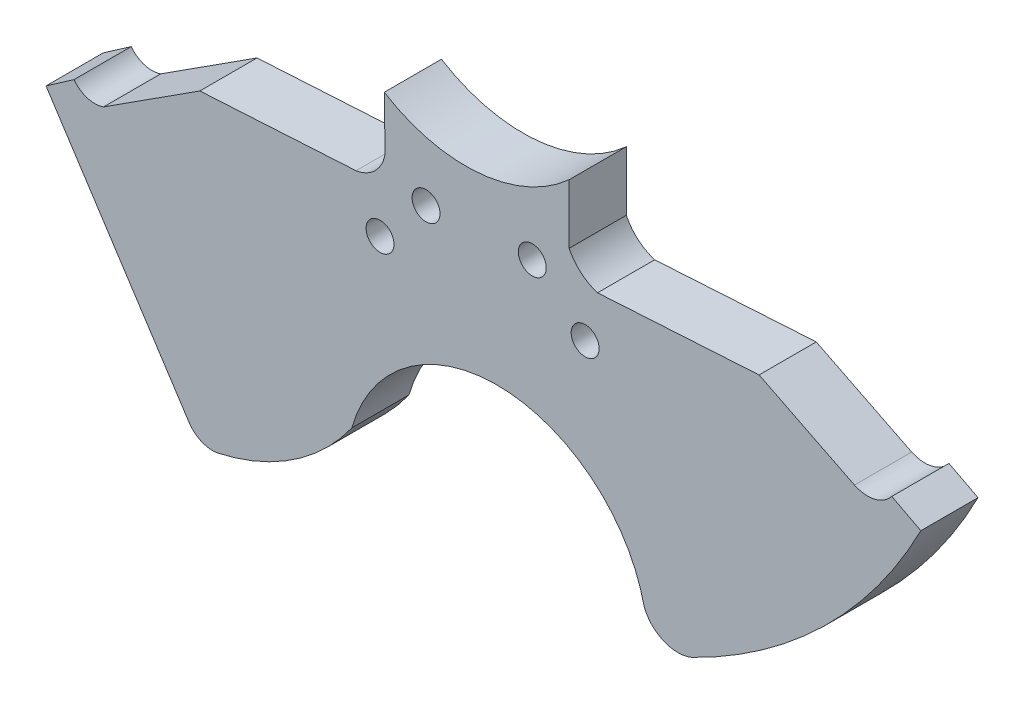
from build123d import *

# Parameters (mm, degrees)
ESBO_O1_R                = 3.175
RESSALTO_EXTRUS_O1_DEPTH = 13


with BuildPart() as part:
    # Esboço1 → Ressalto-extrusão1 (new body)
    with BuildSketch(Plane.XY):
        with BuildLine():
            Line((35.385230037, 10.075467345), (3.022965856, 59.821309359))
            Line((3.022965856, 59.821309359), (9.389592457, 64.241305524))
            ThreePointArc((9.389592457, 64.241305524), (12.424025355, 62.134521854), (16.11664555, 62.238812532))
            Line((16.11664555, 62.238812532), (37.995734983, 76.310625699))
            Line((37.995734983, 76.310625699), (73.510181395, 78.362700262))
            ThreePointArc((73.510181395, 78.362700262), (77.993066809, 80.699414035), (80.140456658, 85.276007717))
            Line((80.140456658, 85.276007717), (79.930003073, 94.415706286))
            Line((79.930003073, 94.415706286), (79.930003073, 97.029046835))
            ThreePointArc((79.930003073, 97.029046835), (101.572218687, 91.878964915), (121.946388489, 100.812163968))
            Line((121.946388489, 100.812163968), (121.946388489, 97.854479056))
            Line((121.946388489, 97.854479056), (121.946388489, 87.306940797))
            ThreePointArc((121.946388489, 87.306940797), (124.605004373, 83.87722317), (128.400566482, 81.773676237))
            Line((128.400566482, 81.773676237), (165.135958914, 83.971302002))
            Line((165.135958914, 83.971302002), (186.825026221, 73.136677472))
            ThreePointArc((186.825026221, 73.136677472), (191.417140339, 72.651683009), (195.305426608, 75.142458308))
            Line((195.305426608, 75.142458308), (201.904648359, 71.689614729))
            ThreePointArc((201.904648359, 71.689614729), (180.384547639, 42.366647273), (150.812504997, 21.190116644))
            ThreePointArc((150.812504997, 21.190116644), (150.313679981, 20.942400372), (149.813666262, 20.697092344))
            ThreePointArc((149.813666262, 20.697092344), (143.468376798, 20.722988132), (139.020600507, 25.248543905))
            ThreePointArc((139.020600507, 25.248543905), (106.562536674, 52.191838172), (72.546533139, 27.244322919))
            ThreePointArc((72.546533139, 27.244322919), (59.147798476, 14.281047119), (41.970794252, 7.033762392))
            ThreePointArc((41.970794252, 7.033762392), (38.439332559, 7.432489412), (35.662068876, 9.64992292))
            Line((35.662068876, 9.64992292), (35.385230037, 10.075467345))
        make_face()
        with Locations((89.421948725, 79.437523552)):
            Circle(ESBO_O1_R, mode=Mode.SUBTRACT)
        with Locations((113.572558486, 80.849829661)):
            Circle(ESBO_O1_R, mode=Mode.SUBTRACT)
        with Locations((78.965142383, 68.179773497)):
            Circle(ESBO_O1_R, mode=Mode.SUBTRACT)
        with Locations((125.590943677, 70.946640577)):
            Circle(ESBO_O1_R, mode=Mode.SUBTRACT)
    extrude(amount=RESSALTO_EXTRUS_O1_DEPTH)


solid = part.part
